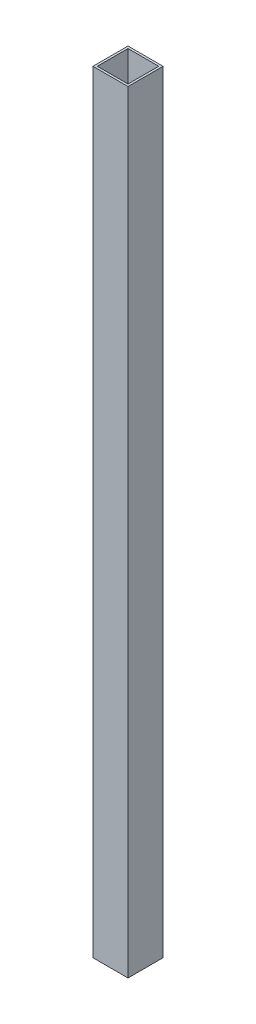
from build123d import *

# Parameters (mm, degrees)
SKETCH1_W           = 25.4
SKETCH1_H           = 25.4
SKETCH1_W_2         = 22.225
SKETCH1_H_2         = 22.225
BOSS_EXTRUDE1_DEPTH = 558.8


with BuildPart() as part:
    # Sketch1 → Boss-Extrude1 (new body)
    with BuildSketch(Plane(origin=(0, 0, 0), x_dir=(1, 0, 0), z_dir=(0, 1, 0))):
        Rectangle(SKETCH1_W, SKETCH1_H)
        Rectangle(SKETCH1_W_2, SKETCH1_H_2, mode=Mode.SUBTRACT)
    extrude(amount=BOSS_EXTRUDE1_DEPTH)


solid = part.part
